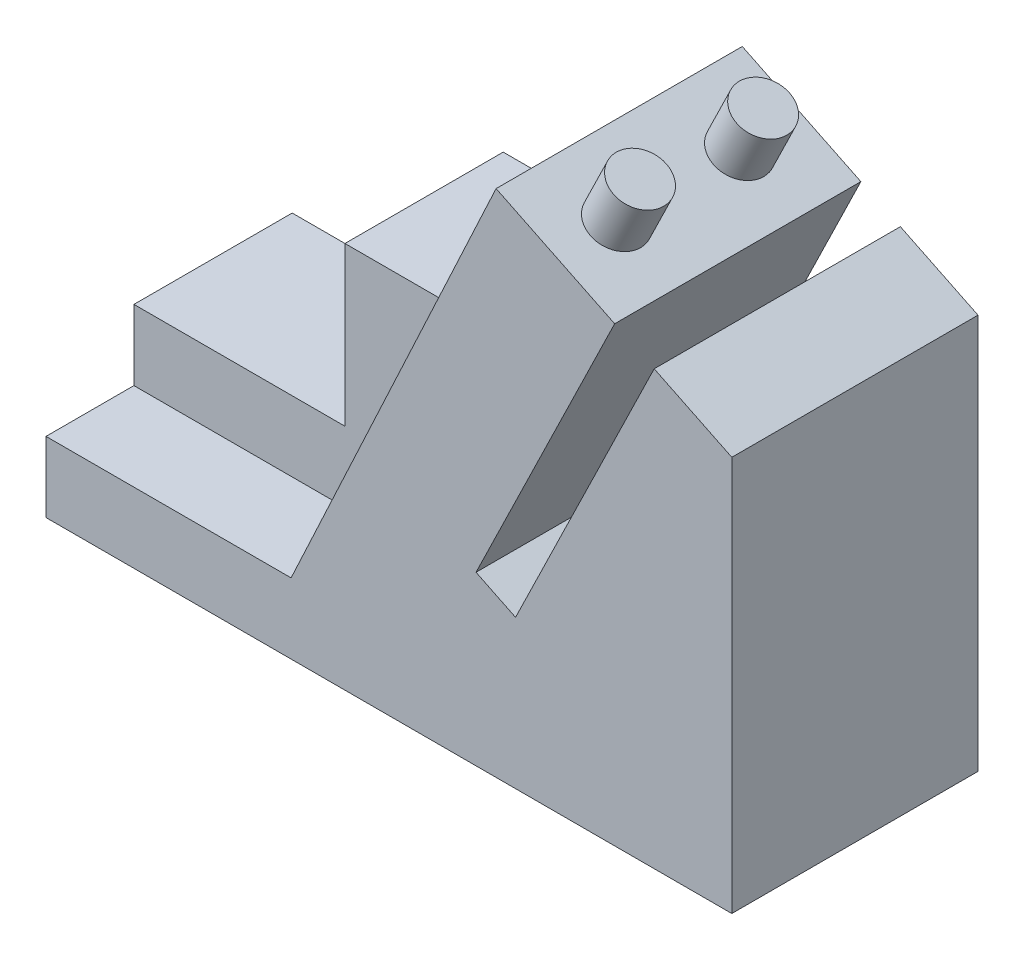
from build123d import *

# Parameters (mm, degrees)
BOSS_EXTRUDE1_DEPTH = 28
BOSS_EXTRUDE2_DEPTH = 18
SKETCH3_R           = 3
BOSS_EXTRUDE3_DEPTH = 6


with BuildPart() as part:
    # Sketch1 → Boss-Extrude1 (new body)
    with BuildSketch(Plane.XY):
        Polygon((0, 0), (78, 0), (78, 44.939392106), (69.171181172, 49.240611534), (53.404281934, 16.876976256), (48.90933259, 19.066823373), (64.676231828, 51.430458651), (51.191383796, 58), (27.876000888, 8), (0, 8), align=None)
    extrude(amount=BOSS_EXTRUDE1_DEPTH)

    # Sketch2 → Boss-Extrude2 (add)
    with BuildSketch(Plane(origin=(0, 0, 0), x_dir=(-1, 0, 0), z_dir=(0, 0, -1))):
        Polygon((0, 8), (0, 16), (-24, 16), (-24, 34), (-40, 34), (-27.876000888, 8), align=None)
    extrude(amount=-BOSS_EXTRUDE2_DEPTH)

    # Sketch3 → Boss-Extrude3 (add)
    with BuildSketch(Plane(origin=(32.655733024, 67.030188838, 0), x_dir=(0.898989869, -0.437969423, 0), z_dir=(0.437969423, 0.898989869, 0))):
        with Locations((28.118308854, -21)):
            Circle(SKETCH3_R)
        with Locations((28.118308854, -7)):
            Circle(SKETCH3_R)
    extrude(amount=BOSS_EXTRUDE3_DEPTH)


solid = part.part
